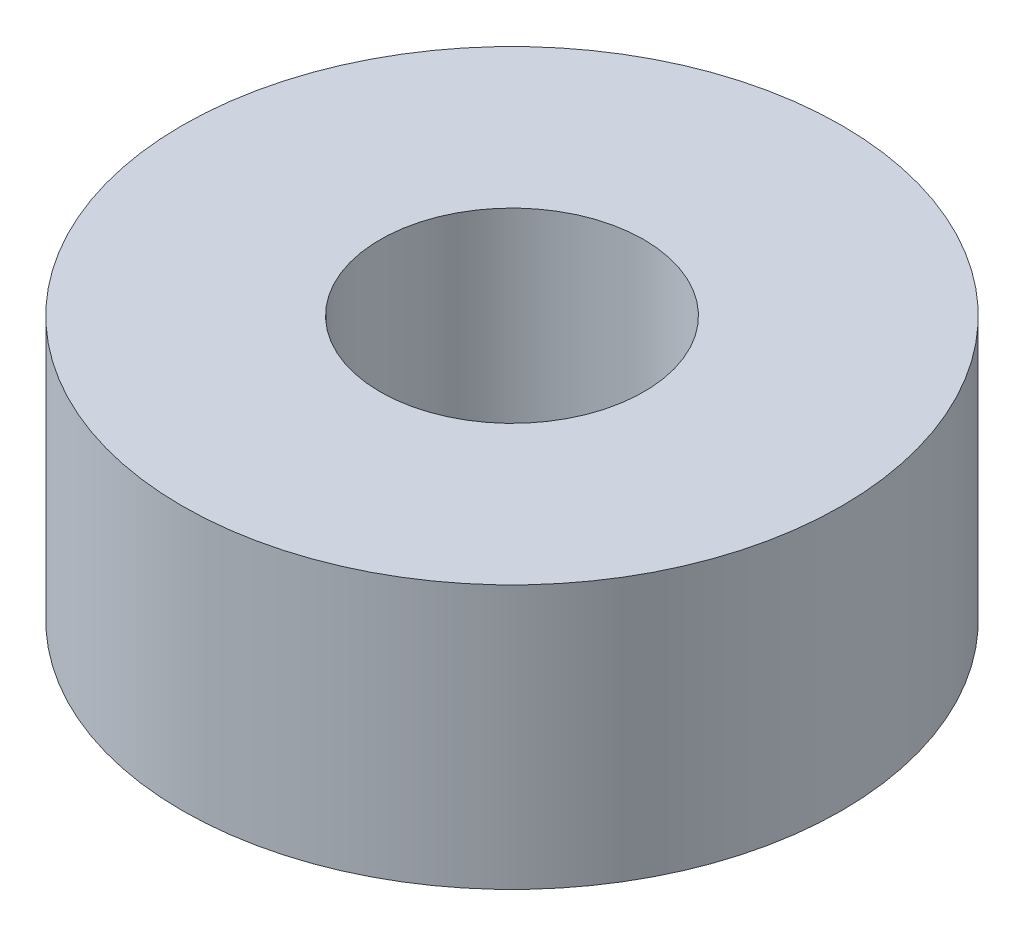
from build123d import *

# Parameters (mm, degrees)
SKETCH1_R           = 2.5
SKETCH1_R_2         = 1
BOSS_EXTRUDE1_DEPTH = 2


with BuildPart() as part:
    # Sketch1 → Boss-Extrude1 (new body)
    with BuildSketch(Plane(origin=(0, 0, 0), x_dir=(1, 0, 0), z_dir=(0, 1, 0))):
        Circle(SKETCH1_R)
        Circle(SKETCH1_R_2, mode=Mode.SUBTRACT)
    extrude(amount=BOSS_EXTRUDE1_DEPTH)


solid = part.part
